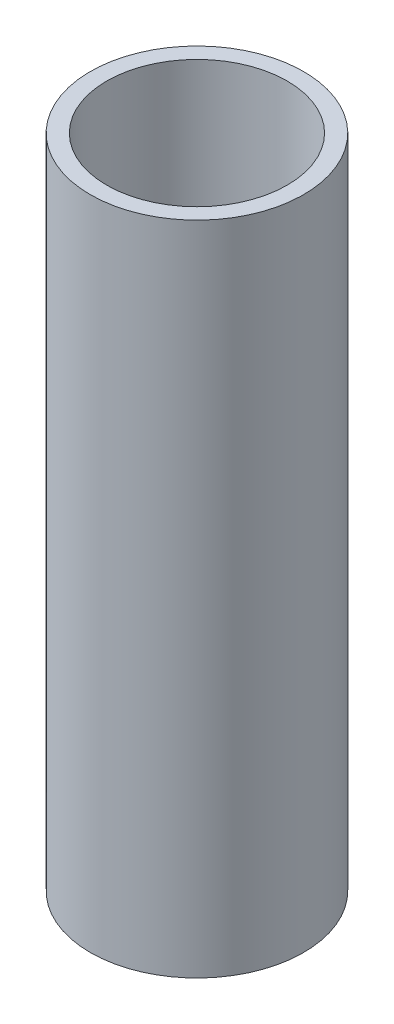
from build123d import *

# Parameters (mm, degrees)
ESQUISSE1_R        = 13
ESQUISSE1_R_2      = 11
BOSS_EXTRU_1_DEPTH = 80


with BuildPart() as part:
    # Esquisse1 → Boss.-Extru.1 (new body)
    with BuildSketch(Plane(origin=(0, 0, 0), x_dir=(1, 0, 0), z_dir=(0, 1, 0))):
        Circle(ESQUISSE1_R)
        Circle(ESQUISSE1_R_2, mode=Mode.SUBTRACT)
    extrude(amount=BOSS_EXTRU_1_DEPTH)


solid = part.part
